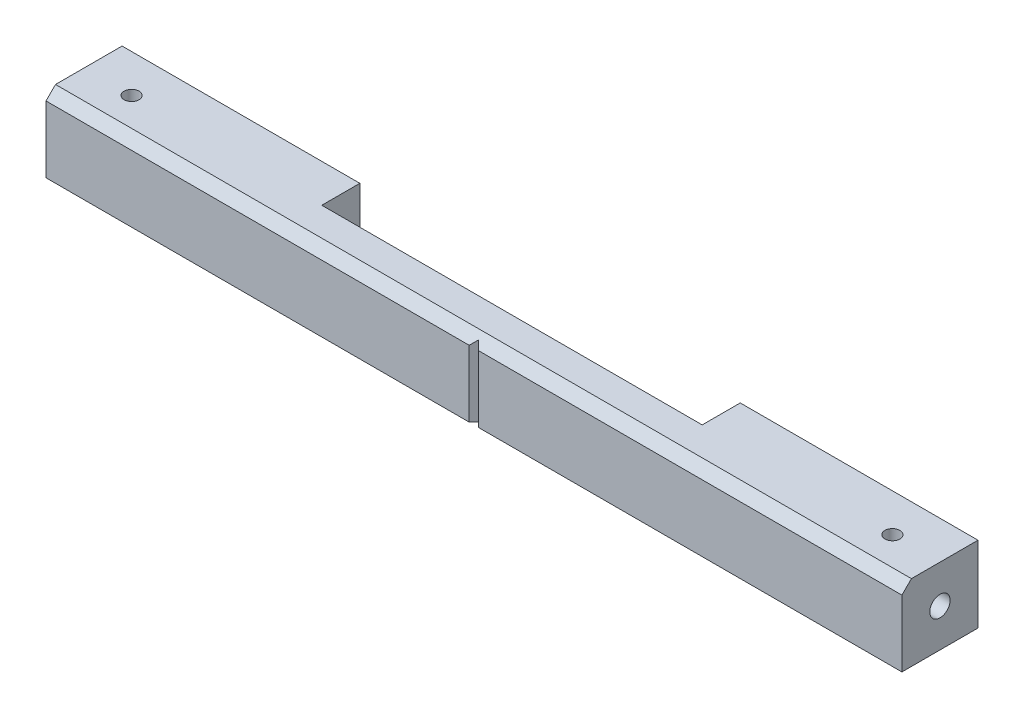
from build123d import *

# Parameters (mm, degrees)
SKETCH1_W                 = 25.4
SKETCH1_H                 = 25.4
EXTRUDE1_DEPTH            = 142.875
CHAMFER1_SIZE             = 3.175
M6X1_0_TAPPED_HOLE1_D     = 5
M6X1_0_TAPPED_HOLE1_DEPTH = 14.986
M6X1_0_TAPPED_HOLE1_TIP   = 1.502151548
CUT_EXTRUDE1_REACH        = 27.4
SKETCH10_W                = 127
SKETCH10_H                = 12.7
CUT_EXTRUDE2_REACH        = 27.4


with BuildPart() as part:
    # Sketch1 → Extrude1 (new body, symmetric)
    with BuildSketch(Plane(origin=(0, 0, 0), x_dir=(0, 0, -1), z_dir=(1, 0, 0))):
        Rectangle(SKETCH1_W, SKETCH1_H)
    extrude(amount=EXTRUDE1_DEPTH, both=True)

    # Sketch2 → M8x1.25 Tapped Hole1 (revolve, cut)
    with BuildSketch(Plane(origin=(142.875, 0, 0), x_dir=(0, 0, -1), z_dir=(0, 1, 0))):
        Polygon((0, 0), (0, 21.804126105), (3.4, 19.7612), (3.4, 0), align=None)
    m8x1_25_tapped_hole1 = revolve(axis=Axis((149.225, 0, 0), (-1, 0, 0)), mode=Mode.SUBTRACT)

    # Mirror1: M8x1.25 Tapped Hole1 across plane
    add(m8x1_25_tapped_hole1.mirror(Plane(origin=(0, 0, 0), x_dir=(0, 0, 1), z_dir=(1, 0, 0))), mode=Mode.SUBTRACT)

    # Chamfer1
    chamfer1_edges = [part.edges().sort_by_distance(p)[0] for p in [
        (0, 12.7, 12.7),
    ]]
    chamfer(chamfer1_edges, length=CHAMFER1_SIZE)

    # M6x1.0 Tapped Hole1
    with Locations(Plane(origin=(0, 12.7, 0), x_dir=(-1, 0, 0), z_dir=(0, 1, 0))):
        with Locations((127, 0), (-127, 0)):
            Hole(M6X1_0_TAPPED_HOLE1_D / 2, depth=M6X1_0_TAPPED_HOLE1_DEPTH)
            with Locations((0, 0, -(M6X1_0_TAPPED_HOLE1_DEPTH + M6X1_0_TAPPED_HOLE1_TIP / 2))):  # 118° drill point
                Cone(0, M6X1_0_TAPPED_HOLE1_D / 2, M6X1_0_TAPPED_HOLE1_TIP, mode=Mode.SUBTRACT)

    # Sketch10 → Cut-Extrude1 (cut, up to next)
    with BuildSketch(Plane(origin=(0, 12.7, 0), x_dir=(1, 0, 0), z_dir=(0, 1, 0)), mode=Mode.PRIVATE) as cut_extrude1_sk1:
        with Locations((0, 6.35)):
            Rectangle(SKETCH10_W, SKETCH10_H)
    cut_extrude1_tool1 = extrude(cut_extrude1_sk1.sketch, amount=-CUT_EXTRUDE1_REACH, mode=Mode.PRIVATE) & part.part
    add(cut_extrude1_tool1.solids().sort_by_distance((0, 12.7, -6.35))[0], mode=Mode.SUBTRACT)

    # Sketch11 → Cut-Extrude2 (cut, up to next)
    with BuildSketch(Plane.XZ.offset(12.7), mode=Mode.PRIVATE) as cut_extrude2_sk1:
        Polygon((-1.5875, 12.7), (1.5875, 12.7), (0, 11.1125), align=None)
    cut_extrude2_tool1 = extrude(cut_extrude2_sk1.sketch, amount=-CUT_EXTRUDE2_REACH, mode=Mode.PRIVATE) & part.part
    add(cut_extrude2_tool1.solids().sort_by_distance((0, -12.7, 12.170833))[0], mode=Mode.SUBTRACT)


solid = part.part
